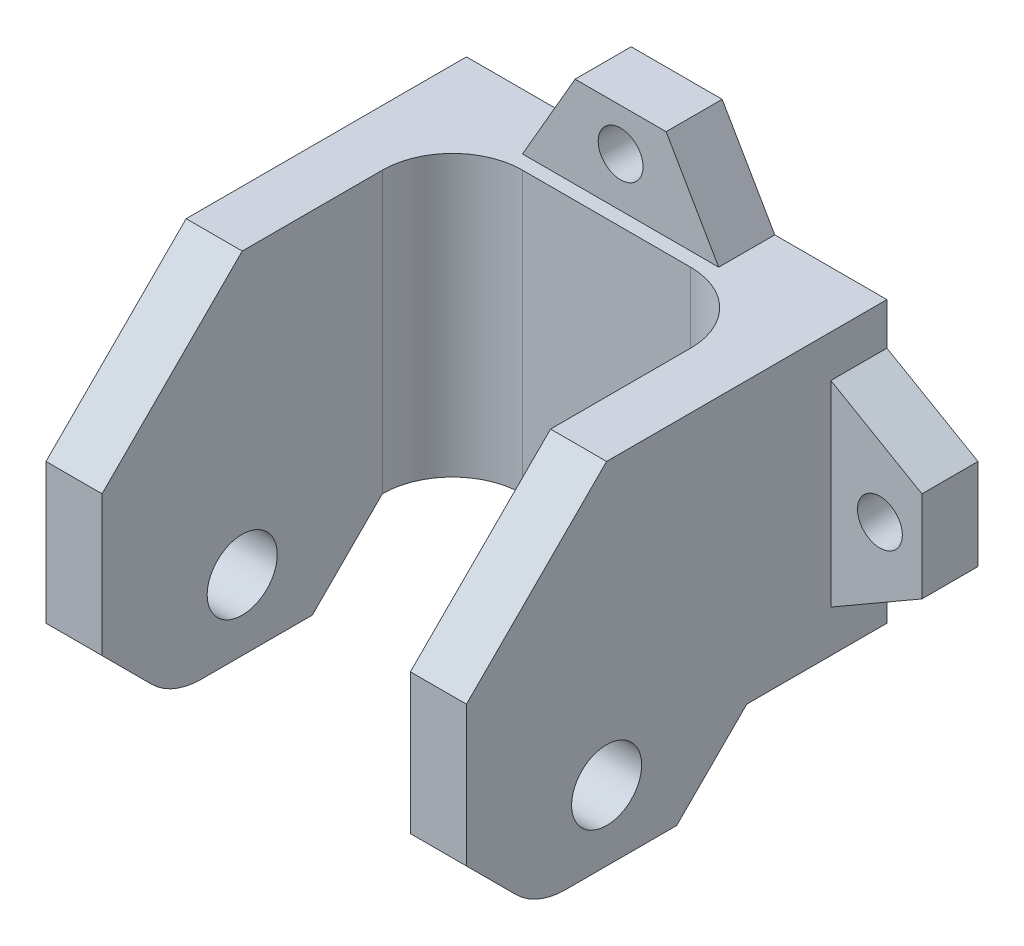
from build123d import *

# Parameters (mm, degrees)
SKETCH1_W             = 30
SKETCH1_H             = 40
BOSS_EXTRUDE1_DEPTH   = 5
SKETCH2_W             = 4
SKETCH2_H             = 40
BOSS_EXTRUDE2_DEPTH   = 25
CHAMFER1_SIZE         = 10
SKETCH3_R             = 2.5
CUT_EXTRUDE1_DEPTH    = 76
CUT_EXTRUDE2_DEPTH    = 76
CHAMFER2_SIZE         = 5
FILLET1_R             = 5
FILLET2_R             = 5
SKETCH5_R             = 1.6
BOSS_EXTRUDE3_DEPTH   = 4
BOSS_EXTRUDE3_2_DEPTH = 4
BOSS_EXTRUDE3_3_DEPTH = 4


with BuildPart() as part:
    # Sketch1 → Boss-Extrude1 (new body)
    with BuildSketch(Plane.XY):
        with Locations((0, -65)):
            Rectangle(SKETCH1_W, SKETCH1_H)
    extrude(amount=BOSS_EXTRUDE1_DEPTH)

    # Sketch2 → Boss-Extrude2 (add)
    with BuildSketch(Plane.XY.offset(5)):
        with Locations((-13, -65)):
            Rectangle(SKETCH2_W, SKETCH2_H)
        with Locations((13, -65)):
            Rectangle(SKETCH2_W, SKETCH2_H)
    extrude(amount=BOSS_EXTRUDE2_DEPTH)

    # Chamfer1
    chamfer1_edges = [part.edges().sort_by_distance(p)[0] for p in [
        (-13, -85, 30),
        (-13, -45, 30),
        (13, -45, 30),
        (13, -85, 30),
    ]]
    chamfer(chamfer1_edges, length=CHAMFER1_SIZE)

    # Sketch3 → Cut-Extrude1 (cut)
    with BuildSketch(Plane.ZY.offset(15)):
        with Locations((20, -65)):
            Circle(SKETCH3_R)
    extrude(amount=-CUT_EXTRUDE1_DEPTH, mode=Mode.SUBTRACT)

    # Sketch4 → Cut-Extrude2 (cut)
    with BuildSketch(Plane.ZY.offset(15)):
        Polygon((30, -70), (15, -70), (10, -65), (0, -65), (-4.906165795, -89.804855258), (31.217938956, -87.25505427), align=None)
    extrude(amount=-CUT_EXTRUDE2_DEPTH, mode=Mode.SUBTRACT)

    # Chamfer2
    chamfer2_edges = [part.edges().sort_by_distance(p)[0] for p in [
        (13, -70, 30),
        (-13, -70, 30),
    ]]
    chamfer(chamfer2_edges, length=CHAMFER2_SIZE)

    # Fillet1
    fillet1_edges = [part.edges().sort_by_distance(p)[0] for p in [
        (11, -55, 5),
        (-11, -55, 5),
    ]]
    fillet(fillet1_edges, radius=FILLET1_R)

    # Fillet2
    fillet2_edges = [part.edges().sort_by_distance(p)[0] for p in [
        (-13, -70, 25),
        (13, -70, 25),
    ]]
    fillet(fillet2_edges, radius=FILLET2_R)


with BuildPart() as body_2:
    # Sketch5 → Boss-Extrude3 (new body)
    with BuildSketch(Plane(origin=(0, 0, 0), x_dir=(-1, 0, 0), z_dir=(0, 0, -1))):
        Polygon((7, -45), (3.24722325, -38.5), (-3.24722325, -38.5), (-7, -45), align=None)
        with Locations((0, -41.5)):
            Circle(SKETCH5_R, mode=Mode.SUBTRACT)
    extrude(amount=-BOSS_EXTRUDE3_DEPTH)


with BuildPart() as body_3:
    # Sketch5 → Boss-Extrude3 2 (new body)
    with BuildSketch(Plane(origin=(0, 0, 0), x_dir=(-1, 0, 0), z_dir=(0, 0, -1))):
        Polygon((15, -48), (21.5, -51.75277675), (21.5, -58.24722325), (15, -62), align=None)
        with Locations((18.5, -55)):
            Circle(SKETCH5_R, mode=Mode.SUBTRACT)
    extrude(amount=-BOSS_EXTRUDE3_2_DEPTH)


with BuildPart() as body_4:
    # Sketch5 → Boss-Extrude3 3 (new body)
    with BuildSketch(Plane(origin=(0, 0, 0), x_dir=(-1, 0, 0), z_dir=(0, 0, -1))):
        Polygon((-15, -62), (-15, -48), (-21.5, -51.75277675), (-21.5, -58.24722325), align=None)
        with Locations((-18.5, -55)):
            Circle(SKETCH5_R, mode=Mode.SUBTRACT)
    extrude(amount=-BOSS_EXTRUDE3_3_DEPTH)


solid = Compound([part.part, body_2.part, body_3.part, body_4.part])
